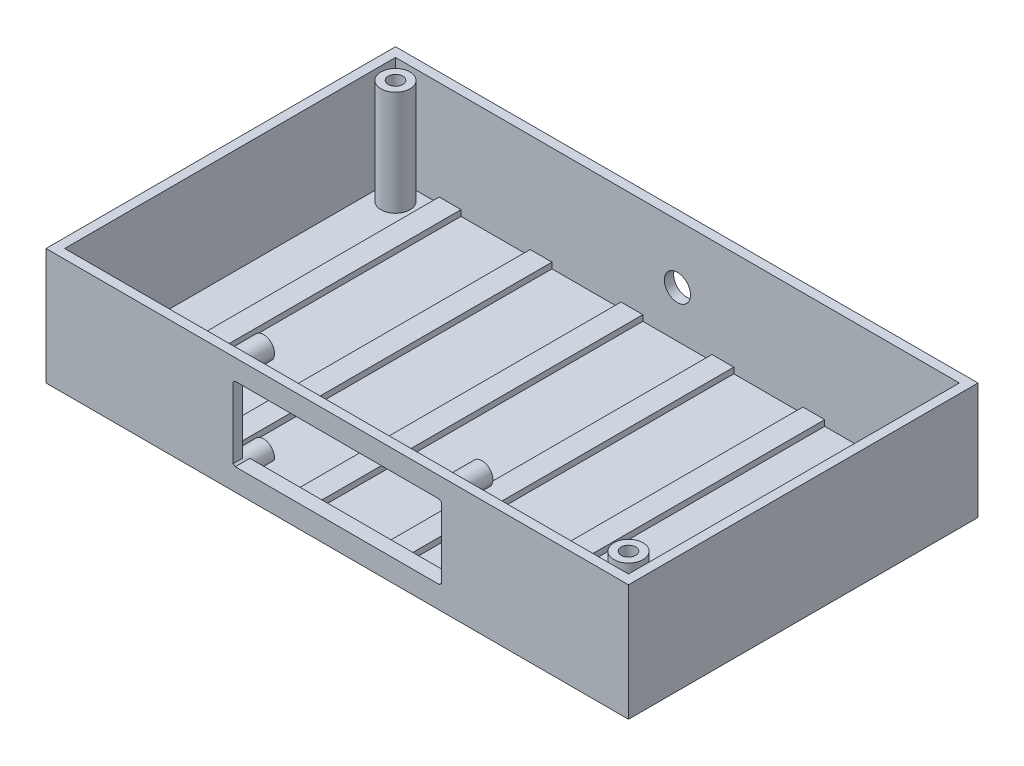
from build123d import *

# Parameters (mm, degrees)
CROQUIS1_W                   = 200
CROQUIS1_H                   = 120
SALIENTE_EXTRUIR1_DEPTH      = 40
CROQUIS2_W                   = 193.6
CROQUIS2_H                   = 113.6
CORTAR_EXTRUIR1_DEPTH        = 36
CROQUIS3_W                   = 71.5
CROQUIS3_H                   = 25.4
CORTAR_EXTRUIR2_DEPTH        = 3.5
CROQUIS4_R                   = 3.75
SALIENTE_EXTRUIR2_DEPTH      = 12.2
CROQUIS5_W                   = 71.5
CROQUIS5_H                   = 4
SALIENTE_EXTRUIR3_DEPTH      = 5
SALIENTE_EXTRUIR4_DEPTH      = 2
SALIENTE_EXTRUIR4_DEPTH_BACK = 5
CROQUIS6_W                   = 7.5
CROQUIS6_H                   = 113.6
CROQUIS7_R                   = 4.5
CORTAR_EXTRUIR3_DEPTH        = 3.3
CROQUIS6_5_R                 = 5
SALIENTE_EXTRUIR5_DEPTH      = 36
SALIENTE_EXTRUIR6_DEPTH      = 5
SALIENTE_EXTRUIR6_DEPTH_BACK = 5
CROQUIS6_6_R                 = 5
CROQUIS8_R                   = 2.5
CORTAR_EXTRUIR4_DEPTH        = 20
CROQUIS9_R                   = 2.5
CORTAR_EXTRUIR5_DEPTH        = 121.66896867


with BuildPart() as part:
    # Croquis1 → Saliente-Extruir1 (new body)
    with BuildSketch(Plane(origin=(0, 0, 0), x_dir=(1, 0, 0), z_dir=(0, 1, 0))):
        Rectangle(CROQUIS1_W, CROQUIS1_H)
    extrude(amount=SALIENTE_EXTRUIR1_DEPTH)

    # Croquis2 → Cortar-Extruir1 (cut)
    with BuildSketch(Plane(origin=(0, 40, 0), x_dir=(1, 0, 0), z_dir=(0, 1, 0))):
        Rectangle(CROQUIS2_W, CROQUIS2_H)
    extrude(amount=-CORTAR_EXTRUIR1_DEPTH, mode=Mode.SUBTRACT)

    # Croquis3 → Cortar-Extruir2 (cut)
    with BuildSketch(Plane.XY.offset(60)):
        with Locations((0, 20.3)):
            Rectangle(CROQUIS3_W, CROQUIS3_H)
    extrude(amount=-CORTAR_EXTRUIR2_DEPTH, mode=Mode.SUBTRACT)

    # Croquis4 → Saliente-Extruir2 (add)
    with BuildSketch(Plane.XY.offset(60)):
        with Locations((-37.5, 35.8)):
            Circle(CROQUIS4_R)
        with Locations((37.5, 35.8)):
            Circle(CROQUIS4_R)
        with Locations((37.5, 4.8)):
            Circle(CROQUIS4_R)
        with Locations((-37.5, 4.8)):
            Circle(CROQUIS4_R)
    extrude(amount=-SALIENTE_EXTRUIR2_DEPTH)

    # Croquis5 → Saliente-Extruir3 (add)
    with BuildSketch(Plane.XY.offset(60)):
        with Locations((0, 5.6)):
            Rectangle(CROQUIS5_W, CROQUIS5_H)
        with Locations((0, 35)):
            Rectangle(CROQUIS5_W, CROQUIS5_H)
    extrude(amount=-SALIENTE_EXTRUIR3_DEPTH)

    # Croquis6 → Saliente-Extruir4 (add, two sides: drawn at the far end of the back side and taken through both)
    with BuildSketch(Plane(origin=(0, 4, 0), x_dir=(1, 0, 0), z_dir=(0, 1, 0)).offset(-SALIENTE_EXTRUIR4_DEPTH_BACK)):
        with Locations((-78.05, 0)):
            Rectangle(CROQUIS6_W, CROQUIS6_H)
        with Locations((-46.83, 0)):
            Rectangle(CROQUIS6_W, CROQUIS6_H)
        with Locations((-15.61, 0)):
            Rectangle(CROQUIS6_W, CROQUIS6_H)
        with Locations((15.61, 0)):
            Rectangle(CROQUIS6_W, CROQUIS6_H)
        with Locations((46.83, 0)):
            Rectangle(CROQUIS6_W, CROQUIS6_H)
        with Locations((78.05, 0)):
            Rectangle(CROQUIS6_W, CROQUIS6_H)
    extrude(amount=SALIENTE_EXTRUIR4_DEPTH + SALIENTE_EXTRUIR4_DEPTH_BACK)

    # Croquis7 → Cortar-Extruir3 (cut)
    with BuildSketch(Plane(origin=(0, 0, -60), x_dir=(-1, 0, 0), z_dir=(0, 0, -1))):
        with Locations((0, 20)):
            Circle(CROQUIS7_R)
    extrude(amount=-CORTAR_EXTRUIR3_DEPTH, mode=Mode.SUBTRACT)

    # Croquis6_5 → Saliente-Extruir5 (add)
    with BuildSketch(Plane(origin=(0, 4, 0), x_dir=(1, 0, 0), z_dir=(0, 1, 0))):
        with Locations((-90, 50)):
            Circle(CROQUIS6_5_R)
        with Locations((90, -50)):
            Circle(CROQUIS6_5_R)
    extrude(amount=SALIENTE_EXTRUIR5_DEPTH)

    # Croquis6_6 → Saliente-Extruir6 (add, two sides: drawn at the far end of the back side and taken through both)
    with BuildSketch(Plane(origin=(0, 4, 0), x_dir=(1, 0, 0), z_dir=(0, 1, 0)).offset(-SALIENTE_EXTRUIR6_DEPTH_BACK)):
        with Locations((90, 50)):
            Circle(CROQUIS6_6_R)
        with Locations((-90, -50)):
            Circle(CROQUIS6_6_R)
    extrude(amount=SALIENTE_EXTRUIR6_DEPTH + SALIENTE_EXTRUIR6_DEPTH_BACK)

    # Croquis8 → Cortar-Extruir4 (cut)
    with BuildSketch(Plane(origin=(0, 40, 0), x_dir=(1, 0, 0), z_dir=(0, 1, 0))):
        with Locations((-90, 50)):
            Circle(CROQUIS8_R)
        with Locations((90, -50)):
            Circle(CROQUIS8_R)
    extrude(amount=-CORTAR_EXTRUIR4_DEPTH, mode=Mode.SUBTRACT)

    # Croquis9 → Cortar-Extruir5 (cut, through all)
    with BuildSketch(Plane(origin=(0, 9, 0), x_dir=(1, 0, 0), z_dir=(0, 1, 0))):
        with Locations((-90, -50)):
            Circle(CROQUIS9_R)
        with Locations((90, 50)):
            Circle(CROQUIS9_R)
    extrude(amount=-CORTAR_EXTRUIR5_DEPTH, mode=Mode.SUBTRACT)


solid = part.part
